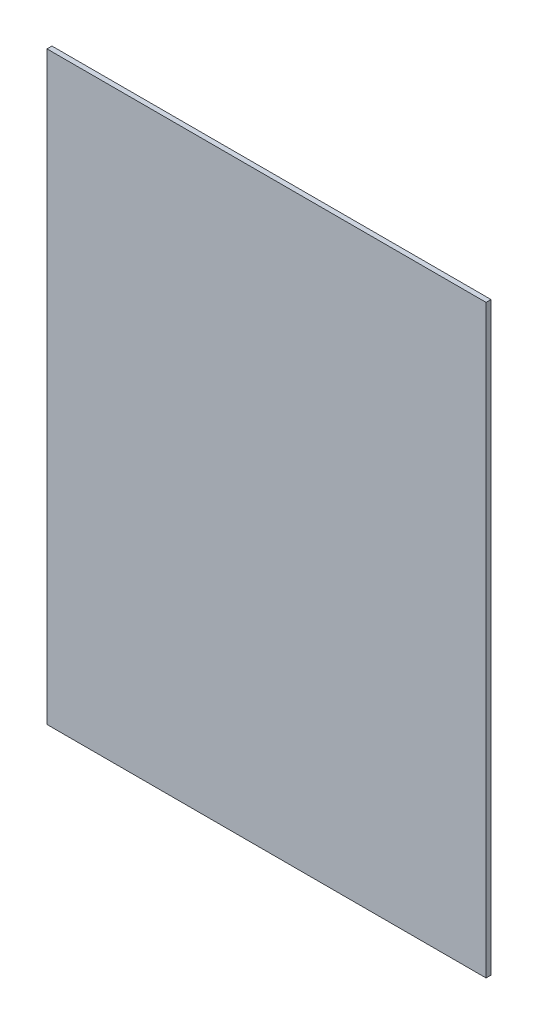
from build123d import *

# Parameters (mm, degrees)
ESQUISSE1_W        = 88.7
ESQUISSE1_H        = 118.2
BOSS_EXTRU_1_DEPTH = 1


with BuildPart() as part:
    # Esquisse1 → Boss.-Extru.1 (new body)
    with BuildSketch(Plane.XY):
        with Locations((44.35, 59.1)):
            Rectangle(ESQUISSE1_W, ESQUISSE1_H)
    extrude(amount=BOSS_EXTRU_1_DEPTH)


solid = part.part
